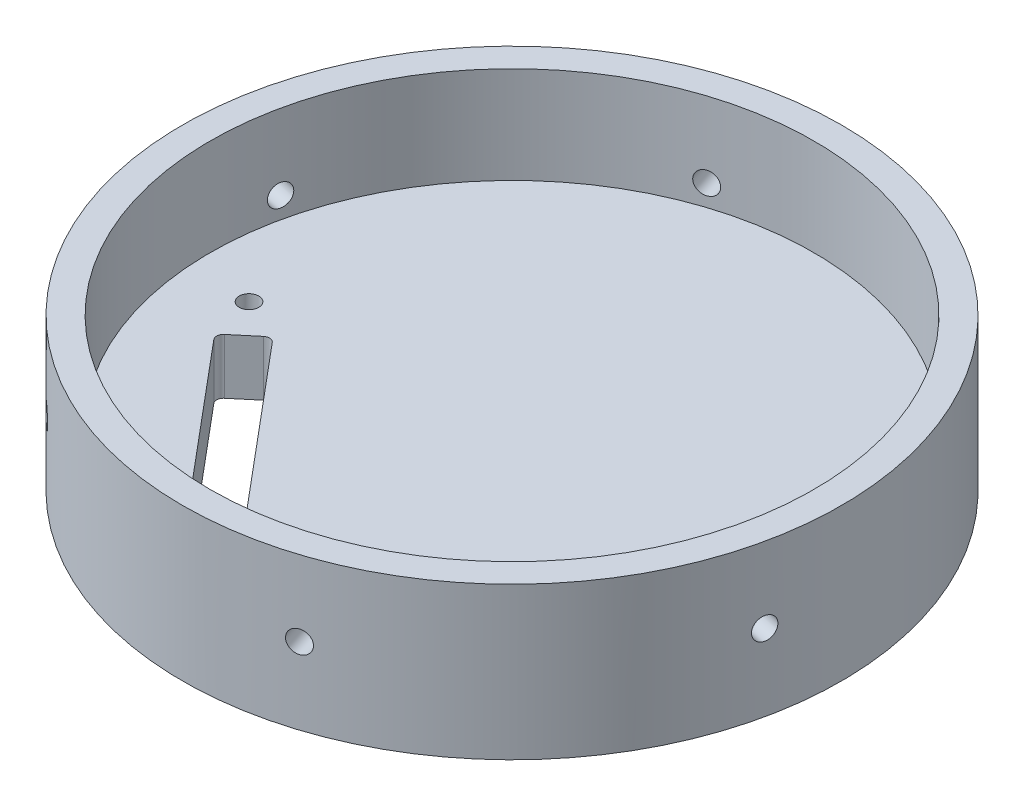
from build123d import *

# Parameters (mm, degrees)
SKETCH1_R                            = 75.692
SKETCH1_R_2                          = 69.342
BOSS_EXTRUDE1_DEPTH                  = 22.225
SKETCH2_R                            = 75.692
BOSS_EXTRUDE2_DEPTH                  = 12.7
TAP_DRILL_FOR_1_4_20_TAP1_AT_2_COUNT = 2
TAP_DRILL_FOR_1_4_20_TAP1_AT_2_PITCH = 53.488399339
CIRPATTERN1_COUNT                    = 6
CUT_EXTRUDE1_DEPTH                   = 13.7000001
FILLET1_R                            = 1.5875
M4_CLEARANCE_HOLE1_D                 = 4.5
M4_CLEARANCE_HOLE1_DEPTH             = 12.7


with BuildPart() as part:
    # Sketch1 → Boss-Extrude1 (new body)
    with BuildSketch(Plane(origin=(0, 0, 0), x_dir=(1, 0, 0), z_dir=(0, 1, 0))):
        Circle(SKETCH1_R)
        Circle(SKETCH1_R_2, mode=Mode.SUBTRACT)
    extrude(amount=BOSS_EXTRUDE1_DEPTH)

    # Sketch2 → Boss-Extrude2 (add)
    with BuildSketch(Plane.XZ):
        Circle(SKETCH2_R)
    extrude(amount=BOSS_EXTRUDE2_DEPTH)

    # Sketch4 → Tap Drill for 1/4-20 Tap1 (revolve, cut)
    with BuildSketch(Plane(origin=(73.997176623, 4.896298223, 15.927859738), x_dir=(0.210429897, 0, -0.97760895), z_dir=(0, 1, 0))):
        Polygon((0, 0), (0, 11.185816902), (2.5527, 9.652), (2.5527, 0), align=None)
    tap_drill_for_1_4_20_tap1 = revolve(axis=Axis((80.204993454, 4.896298223, 17.264089582), (-0.97760895, 0, -0.210429897)), mode=Mode.SUBTRACT)

    # Tap Drill for 1/4-20 Tap1 at 2: Tap Drill for 1/4-20 Tap1 ×2
    with Locations(*[Vector(-0.110438581, 0.851210999, 0.51307227) * (i * TAP_DRILL_FOR_1_4_20_TAP1_AT_2_PITCH) for i in range(1, TAP_DRILL_FOR_1_4_20_TAP1_AT_2_COUNT)]):
        add(tap_drill_for_1_4_20_tap1, mode=Mode.SUBTRACT)

    # CirPattern1: Tap Drill for 1/4-20 Tap1 ×6 about axis
    cirpattern1_axis = Axis((0, 22.225, 0), (0, -1, 0))
    for i in range(1, CIRPATTERN1_COUNT):
        add(tap_drill_for_1_4_20_tap1.rotate(cirpattern1_axis, i * 360 / CIRPATTERN1_COUNT), mode=Mode.SUBTRACT)

    # CirPattern1 copy 1 sketch → CirPattern1 copy 1 (revolve, cut)
    with BuildSketch(Plane(origin=(-3.515628412, 50.426212075, 80.653301416), x_dir=(0.951849134, 0, -0.306566839), z_dir=(0, 1, 0))):
        Polygon((0, 0), (0, 11.185816902), (2.5527, 9.652), (2.5527, 0), align=None)
    revolve(axis=Axis((-1.568928987, 50.426212075, 86.697543415), (-0.306566839, 0, -0.951849134)), mode=Mode.SUBTRACT)

    # CirPattern1 copy 2 sketch → CirPattern1 copy 2 (revolve, cut)
    with BuildSketch(Plane(origin=(-71.605622131, 50.426212075, 37.282027193), x_dir=(0.741419237, 0, 0.671042111), z_dir=(0, 1, 0))):
        Polygon((0, 0), (0, 11.185816902), (2.5527, 9.652), (2.5527, 0), align=None)
    revolve(axis=Axis((-75.866739537, 50.426212075, 41.990039348), (0.671042111, 0, -0.741419237)), mode=Mode.SUBTRACT)

    # CirPattern1 copy 3 sketch → CirPattern1 copy 3 (revolve, cut)
    with BuildSketch(Plane(origin=(-68.089993719, 50.426212075, -43.371274223), x_dir=(-0.210429897, 0, 0.97760895), z_dir=(0, 1, 0))):
        Polygon((0, 0), (0, 11.185816902), (2.5527, 9.652), (2.5527, 0), align=None)
    revolve(axis=Axis((-74.29781055, 50.426212075, -44.707504067), (0.97760895, 0, 0.210429897)), mode=Mode.SUBTRACT)

    # CirPattern1 copy 4 sketch → CirPattern1 copy 4 (revolve, cut)
    with BuildSketch(Plane(origin=(3.515628412, 50.426212075, -80.653301416), x_dir=(-0.951849134, 0, 0.306566839), z_dir=(0, 1, 0))):
        Polygon((0, 0), (0, 11.185816902), (2.5527, 9.652), (2.5527, 0), align=None)
    revolve(axis=Axis((1.568928987, 50.426212075, -86.697543415), (0.306566839, 0, 0.951849134)), mode=Mode.SUBTRACT)

    # CirPattern1 copy 5 sketch → CirPattern1 copy 5 (revolve, cut)
    with BuildSketch(Plane(origin=(71.605622131, 50.426212075, -37.282027193), x_dir=(-0.741419237, 0, -0.671042111), z_dir=(0, 1, 0))):
        Polygon((0, 0), (0, 11.185816902), (2.5527, 9.652), (2.5527, 0), align=None)
    revolve(axis=Axis((75.866739537, 50.426212075, -41.990039348), (-0.671042111, 0, 0.741419237)), mode=Mode.SUBTRACT)

    # Sketch5 → Cut-Extrude1 (cut, through all)
    with BuildSketch(Plane(origin=(0, 0, 0), x_dir=(1, 0, 0), z_dir=(0, 1, 0))):
        Polygon((-52.650183893, -15.647551982), (-45.353610572, -9.525), (-12.7, -48.44005771), (-19.996573321, -54.562609693), align=None)
    extrude(amount=-CUT_EXTRUDE1_DEPTH, mode=Mode.SUBTRACT)

    # Fillet1
    fillet1_edges = [part.edges().sort_by_distance(p)[0] for p in [
        (-19.996573321, -6.35, 54.562609693),
        (-52.650183893, -6.35, 15.647551982),
        (-45.353610572, -6.35, 9.525),
        (-12.7, -6.35, 48.44005771),
    ]]
    fillet(fillet1_edges, radius=FILLET1_R)

    # M4 Clearance Hole1
    with Locations(Plane(origin=(0, 0, 0), x_dir=(1, 0, 0), z_dir=(0, 1, 0))):
        with Locations((-55.124449215, -5.28970267)):
            Hole(M4_CLEARANCE_HOLE1_D / 2, depth=M4_CLEARANCE_HOLE1_DEPTH)


solid = part.part
